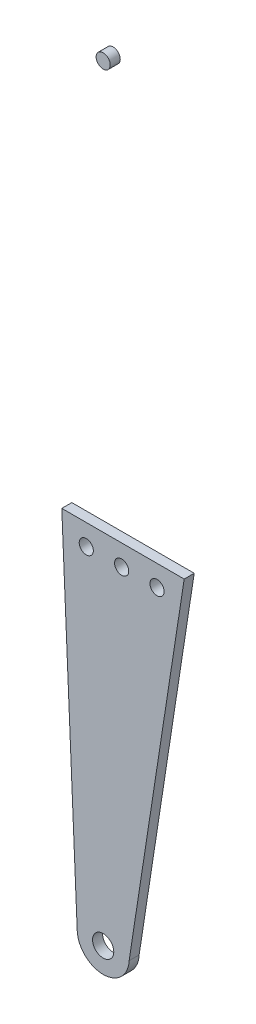
from build123d import *

# Parameters (mm, degrees)
SKETCH1_R             = 3
BOSS_EXTRUDE1_DEPTH   = 4.25
SKETCH1_R_2           = 4.5
BOSS_EXTRUDE1_2_DEPTH = 4.25
SKETCH2_R             = 3
CUT_EXTRUDE1_DEPTH    = 10


with BuildPart() as part:
    # Sketch1 → Boss-Extrude1 (new body)
    with BuildSketch(Plane.XY):
        with Locations((58.910480371, 262.917677392)):
            Circle(SKETCH1_R)
    extrude(amount=BOSS_EXTRUDE1_DEPTH)


with BuildPart() as body_2:
    # Sketch1 → Boss-Extrude1 2 (new body)
    with BuildSketch(Plane.XY):
        with BuildLine():
            Line((41.358559026, 89.803126741), (47.910480371, -62.082322608))
            ThreePointArc((47.910480371, -62.082322608), (58.910480371, -72.618042573), (69.910480371, -62.082322608))
            Line((69.910480371, -62.082322608), (93.272734055, 89.803126741))
            Line((93.272734055, 89.803126741), (41.358559026, 89.803126741))
        make_face()
        with Locations((58.910480371, -62.082322608)):
            Circle(SKETCH1_R_2, mode=Mode.SUBTRACT)
    extrude(amount=BOSS_EXTRUDE1_2_DEPTH)

    # Sketch2 → Cut-Extrude1 (cut)
    with BuildSketch(Plane.XY.offset(4.25)):
        with Locations((51.751152709, 80.917677392)):
            Circle(SKETCH2_R)
        with Locations((66.751152709, 80.917677392)):
            Circle(SKETCH2_R)
        with Locations((81.751152709, 80.917677392)):
            Circle(SKETCH2_R)
    extrude(amount=-CUT_EXTRUDE1_DEPTH, mode=Mode.SUBTRACT)


solid = Compound([part.part, body_2.part])
